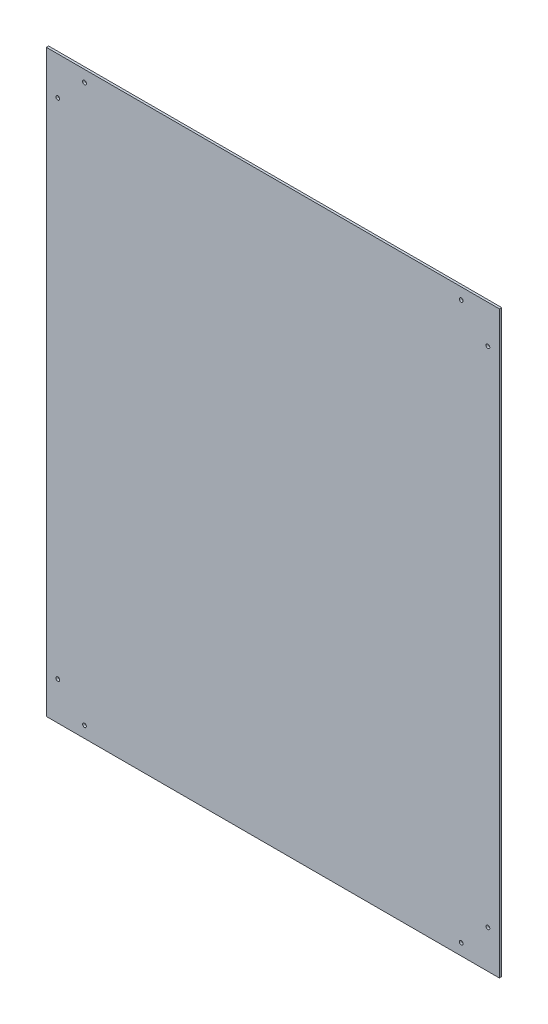
from build123d import *

# Parameters (mm, degrees)
ESQUISSE1_W             = 594
ESQUISSE1_H             = 760
BOSS_EXTRU_1_DEPTH      = 3
ESQUISSE2_R             = 2.5
ENL_V_MAT_EXTRU_1_DEPTH = 3


with BuildPart() as part:
    # Esquisse1 → Boss.-Extru.1 (new body)
    with BuildSketch(Plane.XY):
        with Locations((297, 380)):
            Rectangle(ESQUISSE1_W, ESQUISSE1_H)
    extrude(amount=BOSS_EXTRU_1_DEPTH)

    # Esquisse2 → Enlèv. mat.-Extru.1 (cut)
    with BuildSketch(Plane.XY.offset(3)):
        with Locations((50, 745)):
            Circle(ESQUISSE2_R)
        with Locations((15, 710)):
            Circle(ESQUISSE2_R)
        with Locations((15, 50)):
            Circle(ESQUISSE2_R)
        with Locations((50, 15)):
            Circle(ESQUISSE2_R)
        with Locations((544, 15)):
            Circle(ESQUISSE2_R)
        with Locations((579, 50)):
            Circle(ESQUISSE2_R)
        with Locations((579, 710)):
            Circle(ESQUISSE2_R)
        with Locations((544, 745)):
            Circle(ESQUISSE2_R)
    extrude(amount=-ENL_V_MAT_EXTRU_1_DEPTH, mode=Mode.SUBTRACT)


solid = part.part
